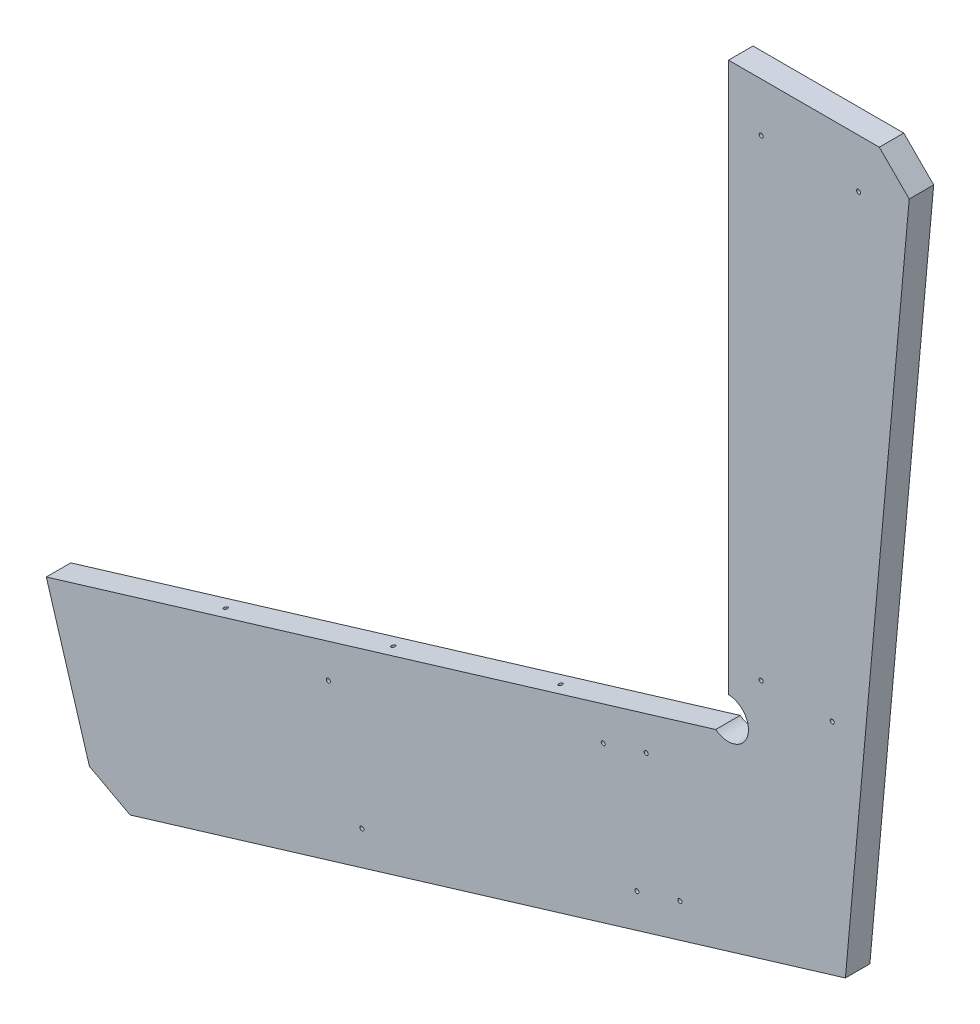
from build123d import *

# Parameters (mm, degrees)
BOSS_EXTRUDE1_DEPTH  = 19.05
CHAMFER1_SIZE2       = 25.4
CHAMFER1_SIZE        = 23.3906272
CHAMFER1_EDGE_2_SIZE = 25.4
HOLE2_D              = 3.175
HOLE2_DEPTH          = 31.75
HOLE2_CSINK_D        = 10.16
HOLE2_CSINK_ANGLE    = 82
HOLE2_TIP            = 0.953866233
HOLE4_D              = 3.175
HOLE4_DEPTH          = 31.75
HOLE4_CSINK_D        = 10.16
HOLE4_CSINK_ANGLE    = 82
HOLE4_TIP            = 0.953866233
HOLE5_D              = 3.175
HOLE5_DEPTH          = 38.1
HOLE5_CSINK_D        = 10.16
HOLE5_CSINK_ANGLE    = 82
HOLE5_TIP            = 0.953866233
HOLE6_D              = 3.175
HOLE6_DEPTH          = 38.1
HOLE6_CSINK_D        = 10.16
HOLE6_CSINK_ANGLE    = 82
HOLE6_TIP            = 0.953866233


with BuildPart() as part:
    # Sketch1 → Boss-Extrude1 (new body)
    with BuildSketch(Plane.XY):
        with BuildLine():
            Line((12.7, 12.7), (12.7, -415.185594934))
            ThreePointArc((12.7, -415.185594934), (27.339445595, -436.32629993), (2.687239133, -443.641454859))
            Line((2.687239133, -443.641454859), (-518.461959982, -601.369999539))
            Line((-518.461959982, -601.369999539), (-477.533889468, -736.6))
            Line((-477.533889468, -736.6), (103.700681611, -560.686301639))
            Line((103.700681611, -560.686301639), (155.492294041, 12.7))
            Line((155.492294041, 12.7), (12.7, 12.7))
        make_face()
    extrude(amount=-BOSS_EXTRUDE1_DEPTH)

    # Chamfer1
    chamfer1_edges = [part.edges().sort_by_distance(p)[0] for p in [
        (155.492294041, 12.7, -9.525),
    ]]
    chamfer(chamfer1_edges, length=CHAMFER1_SIZE, length2=CHAMFER1_SIZE2)

    # Chamfer1 edge 2
    chamfer1_edge_2_edges = [part.edges().sort_by_distance(p)[0] for p in [
        (-477.533889468, -736.6, -9.525),
    ]]
    chamfer(chamfer1_edge_2_edges, length=CHAMFER1_EDGE_2_SIZE)

    # Hole2
    with Locations(Plane(origin=(0, 10.424290059, 165.474999994), x_dir=(0, 0, -1), z_dir=(-1, 0, 0))):
        with Locations((-155.949999994, 107.734820482), (155.949999994, 107.734820482), (155.949999994, 327.755881328), (174.999999994, 85.732714397), (174.999999994, 349.757987412), (-174.999999994, 349.757987412), (-174.999999994, 85.732714397), (-155.949999994, 327.755881328)):
            CounterSinkHole(HOLE2_D / 2, HOLE2_CSINK_D / 2, depth=HOLE2_DEPTH, counter_sink_angle=HOLE2_CSINK_ANGLE)
            with Locations((0, 0, -(HOLE2_DEPTH + HOLE2_TIP / 2))):  # 118° drill point
                Cone(0, HOLE2_D / 2, HOLE2_TIP, mode=Mode.SUBTRACT)

    # Hole4
    with Locations(Plane(origin=(264.696145853, -351.07416346, 165.474999994), x_dir=(0, 0, -1), z_dir=(-0.289678603, 0.957123977, 0))):
        with Locations((174.999999994, 685.961004241), (174.999999994, 549.837259632), (174.999999994, 413.713515022), (81.549999997, 779.649723129), (81.549999997, 652.344645962), (62.499999997, 662.953402392), (62.499999997, 769.040966698), (-62.499999997, 769.040966698), (-62.499999997, 662.953402392), (-81.549999997, 652.344645962), (-81.549999997, 779.649723129), (-174.999999994, 413.713515022), (-174.999999994, 549.837259632), (-174.999999994, 685.961004241), (-82.737499997, 600.384620239), (0, 600.384620239), (82.737499997, 600.384620239), (0, 376.737770337), (-82.737499997, 376.737770337), (82.737499997, 376.737770337)):
            CounterSinkHole(HOLE4_D / 2, HOLE4_CSINK_D / 2, depth=HOLE4_DEPTH, counter_sink_angle=HOLE4_CSINK_ANGLE)
            with Locations((0, 0, -(HOLE4_DEPTH + HOLE4_TIP / 2))):  # 118° drill point
                Cone(0, HOLE4_D / 2, HOLE4_TIP, mode=Mode.SUBTRACT)

    # Hole5
    with Locations(Plane(origin=(155.286738577, 10.424290059, -19.05), x_dir=(-0.089959629, -0.995945413, 0), z_dir=(0, 0, -1))):
        with Locations((46.221112845, 113.488854888), (39.39759596, 37.945520226), (412.28786892, 80.423559293), (407.308516105, 25.297013484), (513.561319184, 161.164706775), (597.46020397, 127.267357003), (610.543339245, 159.649253123), (694.322923815, 367.011001477), (526.644454459, 193.546602895), (610.424039029, 400.908351249)):
            CounterSinkHole(HOLE5_D / 2, HOLE5_CSINK_D / 2, depth=HOLE5_DEPTH, counter_sink_angle=HOLE5_CSINK_ANGLE)
            with Locations((0, 0, -(HOLE5_DEPTH + HOLE5_TIP / 2))):  # 118° drill point
                Cone(0, HOLE5_D / 2, HOLE5_TIP, mode=Mode.SUBTRACT)

    # Hole6
    with Locations(Plane(origin=(-643.705760022, -231.394989772, 165.474999994), x_dir=(0, 0, -1), z_dir=(-0.957123977, -0.289678603, 0))):
        with Locations((-108.649999997, 332.89193461), (108.649999997, 332.89193461), (207.774999994, 332.89193461), (174.999999994, 448.336332751), (135.266666663, 384.042401694), (176.283333328, 384.042401694), (-174.999999994, 448.336332751), (-135.266666663, 384.042401694), (-176.283333328, 384.042401694), (-207.774999994, 332.89193461)):
            CounterSinkHole(HOLE6_D / 2, HOLE6_CSINK_D / 2, depth=HOLE6_DEPTH, counter_sink_angle=HOLE6_CSINK_ANGLE)
            with Locations((0, 0, -(HOLE6_DEPTH + HOLE6_TIP / 2))):  # 118° drill point
                Cone(0, HOLE6_D / 2, HOLE6_TIP, mode=Mode.SUBTRACT)


solid = part.part
